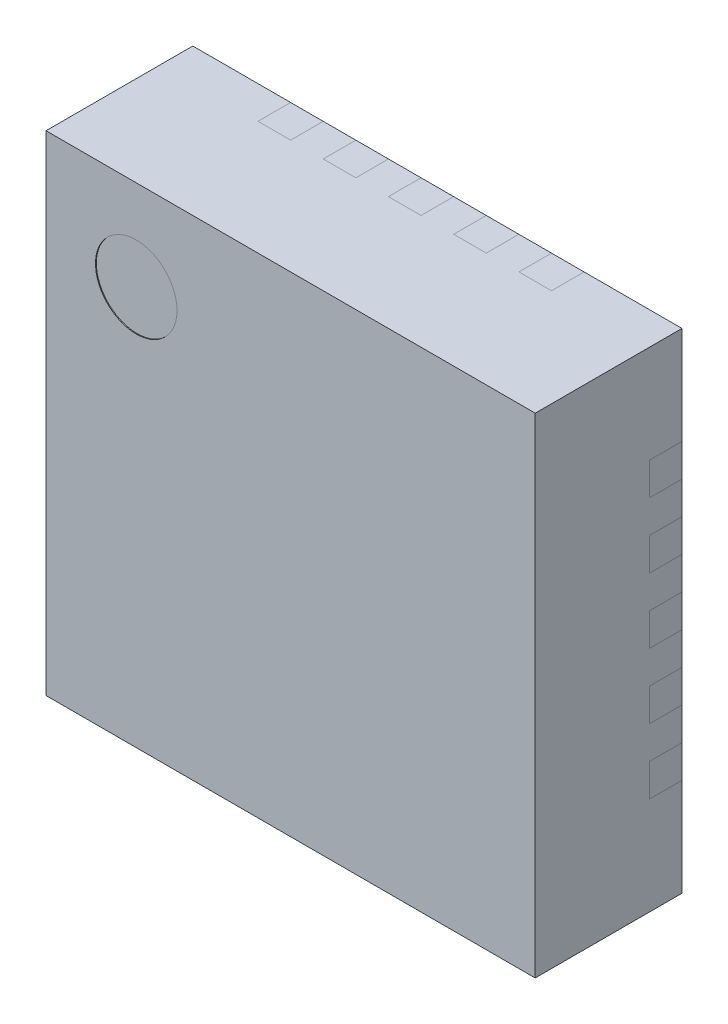
from build123d import *

# Parameters (mm, degrees)
SKETCH1_W              = 3
SKETCH1_H              = 3
BOSS_EXTRUDE1_DEPTH    = 0.9
SKETCH2_W              = 0.2
SKETCH2_H              = 0.2
CUT_EXTRUDE1_DEPTH     = 0.5
CIRPATTERN1_COUNT      = 4
SKETCH4_R              = 0.25
CUT_EXTRUDE2_DEPTH     = 0.005
SKETCH5_W              = 0.5
SKETCH5_H              = 0.2
BOSS_EXTRUDE2_DEPTH    = 0.2
BOSS_EXTRUDE2_2_DEPTH  = 0.2
BOSS_EXTRUDE2_3_DEPTH  = 0.2
BOSS_EXTRUDE2_4_DEPTH  = 0.2
BOSS_EXTRUDE2_5_DEPTH  = 0.2
SKETCH5_W_2            = 0.2
SKETCH5_H_2            = 0.5
BOSS_EXTRUDE2_6_DEPTH  = 0.2
BOSS_EXTRUDE2_7_DEPTH  = 0.2
BOSS_EXTRUDE2_8_DEPTH  = 0.2
BOSS_EXTRUDE2_9_DEPTH  = 0.2
BOSS_EXTRUDE2_10_DEPTH = 0.2
BOSS_EXTRUDE2_11_DEPTH = 0.2
BOSS_EXTRUDE2_12_DEPTH = 0.2
BOSS_EXTRUDE2_13_DEPTH = 0.2
BOSS_EXTRUDE2_14_DEPTH = 0.2
BOSS_EXTRUDE2_15_DEPTH = 0.2
BOSS_EXTRUDE2_16_DEPTH = 0.2
BOSS_EXTRUDE2_17_DEPTH = 0.2
BOSS_EXTRUDE2_18_DEPTH = 0.2
BOSS_EXTRUDE2_19_DEPTH = 0.2
BOSS_EXTRUDE2_20_DEPTH = 0.2


with BuildPart() as part:
    # Sketch1 → Boss-Extrude1 (new body)
    with BuildSketch(Plane.XY):
        Rectangle(SKETCH1_W, SKETCH1_H)
    extrude(amount=BOSS_EXTRUDE1_DEPTH)

    # Sketch2 → Cut-Extrude1 (cut)
    with BuildSketch(Plane(origin=(1.5, 0, 0), x_dir=(0, 0, -1), z_dir=(1, 0, 0))):
        with Locations((-0.1, -0.8)):
            Rectangle(SKETCH2_W, SKETCH2_H)
        with Locations((-0.1, -0.4)):
            Rectangle(SKETCH2_W, SKETCH2_H)
        with Locations((-0.1, 0)):
            Rectangle(SKETCH2_W, SKETCH2_H)
        with Locations((-0.1, 0.4)):
            Rectangle(SKETCH2_W, SKETCH2_H)
        with Locations((-0.1, 0.8)):
            Rectangle(SKETCH2_W, SKETCH2_H)
        with Locations((0.1, 0.8)):
            Rectangle(SKETCH2_W, SKETCH2_H)
        with Locations((0.1, 0.4)):
            Rectangle(SKETCH2_W, SKETCH2_H)
        with Locations((0.1, 0)):
            Rectangle(SKETCH2_W, SKETCH2_H)
        with Locations((0.1, -0.4)):
            Rectangle(SKETCH2_W, SKETCH2_H)
        with Locations((0.1, -0.8)):
            Rectangle(SKETCH2_W, SKETCH2_H)
    cut_extrude1 = extrude(amount=-CUT_EXTRUDE1_DEPTH, mode=Mode.SUBTRACT)

    # CirPattern1: Cut-Extrude1 ×4 about axis
    cirpattern1_axis = Axis((0, 0, 0), (0, 0, 1))
    for i in range(1, CIRPATTERN1_COUNT):
        add(cut_extrude1.rotate(cirpattern1_axis, i * 360 / CIRPATTERN1_COUNT), mode=Mode.SUBTRACT)

    # Sketch4 → Cut-Extrude2 (cut)
    with BuildSketch(Plane.XY.offset(0.9)):
        with Locations((-0.946643178, 0.946643178)):
            Circle(SKETCH4_R)
    extrude(amount=-CUT_EXTRUDE2_DEPTH, mode=Mode.SUBTRACT)


with BuildPart() as body_2:
    # Sketch5 → Boss-Extrude2 (new body)
    with BuildSketch(Plane(origin=(0, 0, 0.2), x_dir=(-1, 0, 0), z_dir=(0, 0, -1))):
        with Locations((-1.25, 0.8)):
            Rectangle(SKETCH5_W, SKETCH5_H)
    extrude(amount=BOSS_EXTRUDE2_DEPTH)


with BuildPart() as body_3:
    # Sketch5 → Boss-Extrude2 2 (new body)
    with BuildSketch(Plane(origin=(0, 0, 0.2), x_dir=(-1, 0, 0), z_dir=(0, 0, -1))):
        with Locations((-1.25, 0.4)):
            Rectangle(SKETCH5_W, SKETCH5_H)
    extrude(amount=BOSS_EXTRUDE2_2_DEPTH)


with BuildPart() as body_4:
    # Sketch5 → Boss-Extrude2 3 (new body)
    with BuildSketch(Plane(origin=(0, 0, 0.2), x_dir=(-1, 0, 0), z_dir=(0, 0, -1))):
        with Locations((-1.25, 0)):
            Rectangle(SKETCH5_W, SKETCH5_H)
    extrude(amount=BOSS_EXTRUDE2_3_DEPTH)


with BuildPart() as body_5:
    # Sketch5 → Boss-Extrude2 4 (new body)
    with BuildSketch(Plane(origin=(0, 0, 0.2), x_dir=(-1, 0, 0), z_dir=(0, 0, -1))):
        with Locations((-1.25, -0.4)):
            Rectangle(SKETCH5_W, SKETCH5_H)
    extrude(amount=BOSS_EXTRUDE2_4_DEPTH)


with BuildPart() as body_6:
    # Sketch5 → Boss-Extrude2 5 (new body)
    with BuildSketch(Plane(origin=(0, 0, 0.2), x_dir=(-1, 0, 0), z_dir=(0, 0, -1))):
        with Locations((-1.25, -0.8)):
            Rectangle(SKETCH5_W, SKETCH5_H)
    extrude(amount=BOSS_EXTRUDE2_5_DEPTH)


with BuildPart() as body_7:
    # Sketch5 → Boss-Extrude2 6 (new body)
    with BuildSketch(Plane(origin=(0, 0, 0.2), x_dir=(-1, 0, 0), z_dir=(0, 0, -1))):
        with Locations((-0.8, -1.25)):
            Rectangle(SKETCH5_W_2, SKETCH5_H_2)
    extrude(amount=BOSS_EXTRUDE2_6_DEPTH)


with BuildPart() as body_8:
    # Sketch5 → Boss-Extrude2 7 (new body)
    with BuildSketch(Plane(origin=(0, 0, 0.2), x_dir=(-1, 0, 0), z_dir=(0, 0, -1))):
        with Locations((-0.4, -1.25)):
            Rectangle(SKETCH5_W_2, SKETCH5_H_2)
    extrude(amount=BOSS_EXTRUDE2_7_DEPTH)


with BuildPart() as body_9:
    # Sketch5 → Boss-Extrude2 8 (new body)
    with BuildSketch(Plane(origin=(0, 0, 0.2), x_dir=(-1, 0, 0), z_dir=(0, 0, -1))):
        with Locations((0, -1.25)):
            Rectangle(SKETCH5_W_2, SKETCH5_H_2)
    extrude(amount=BOSS_EXTRUDE2_8_DEPTH)


with BuildPart() as body_10:
    # Sketch5 → Boss-Extrude2 9 (new body)
    with BuildSketch(Plane(origin=(0, 0, 0.2), x_dir=(-1, 0, 0), z_dir=(0, 0, -1))):
        with Locations((0.4, -1.25)):
            Rectangle(SKETCH5_W_2, SKETCH5_H_2)
    extrude(amount=BOSS_EXTRUDE2_9_DEPTH)


with BuildPart() as body_11:
    # Sketch5 → Boss-Extrude2 10 (new body)
    with BuildSketch(Plane(origin=(0, 0, 0.2), x_dir=(-1, 0, 0), z_dir=(0, 0, -1))):
        with Locations((0.8, -1.25)):
            Rectangle(SKETCH5_W_2, SKETCH5_H_2)
    extrude(amount=BOSS_EXTRUDE2_10_DEPTH)


with BuildPart() as body_12:
    # Sketch5 → Boss-Extrude2 11 (new body)
    with BuildSketch(Plane(origin=(0, 0, 0.2), x_dir=(-1, 0, 0), z_dir=(0, 0, -1))):
        with Locations((1.25, -0.8)):
            Rectangle(SKETCH5_W, SKETCH5_H)
    extrude(amount=BOSS_EXTRUDE2_11_DEPTH)


with BuildPart() as body_13:
    # Sketch5 → Boss-Extrude2 12 (new body)
    with BuildSketch(Plane(origin=(0, 0, 0.2), x_dir=(-1, 0, 0), z_dir=(0, 0, -1))):
        with Locations((1.25, -0.4)):
            Rectangle(SKETCH5_W, SKETCH5_H)
    extrude(amount=BOSS_EXTRUDE2_12_DEPTH)


with BuildPart() as body_14:
    # Sketch5 → Boss-Extrude2 13 (new body)
    with BuildSketch(Plane(origin=(0, 0, 0.2), x_dir=(-1, 0, 0), z_dir=(0, 0, -1))):
        with Locations((1.25, 0)):
            Rectangle(SKETCH5_W, SKETCH5_H)
    extrude(amount=BOSS_EXTRUDE2_13_DEPTH)


with BuildPart() as body_15:
    # Sketch5 → Boss-Extrude2 14 (new body)
    with BuildSketch(Plane(origin=(0, 0, 0.2), x_dir=(-1, 0, 0), z_dir=(0, 0, -1))):
        with Locations((1.25, 0.4)):
            Rectangle(SKETCH5_W, SKETCH5_H)
    extrude(amount=BOSS_EXTRUDE2_14_DEPTH)


with BuildPart() as body_16:
    # Sketch5 → Boss-Extrude2 15 (new body)
    with BuildSketch(Plane(origin=(0, 0, 0.2), x_dir=(-1, 0, 0), z_dir=(0, 0, -1))):
        with Locations((1.25, 0.8)):
            Rectangle(SKETCH5_W, SKETCH5_H)
    extrude(amount=BOSS_EXTRUDE2_15_DEPTH)


with BuildPart() as body_17:
    # Sketch5 → Boss-Extrude2 16 (new body)
    with BuildSketch(Plane(origin=(0, 0, 0.2), x_dir=(-1, 0, 0), z_dir=(0, 0, -1))):
        with Locations((0.8, 1.25)):
            Rectangle(SKETCH5_W_2, SKETCH5_H_2)
    extrude(amount=BOSS_EXTRUDE2_16_DEPTH)


with BuildPart() as body_18:
    # Sketch5 → Boss-Extrude2 17 (new body)
    with BuildSketch(Plane(origin=(0, 0, 0.2), x_dir=(-1, 0, 0), z_dir=(0, 0, -1))):
        with Locations((0.4, 1.25)):
            Rectangle(SKETCH5_W_2, SKETCH5_H_2)
    extrude(amount=BOSS_EXTRUDE2_17_DEPTH)


with BuildPart() as body_19:
    # Sketch5 → Boss-Extrude2 18 (new body)
    with BuildSketch(Plane(origin=(0, 0, 0.2), x_dir=(-1, 0, 0), z_dir=(0, 0, -1))):
        with Locations((0, 1.25)):
            Rectangle(SKETCH5_W_2, SKETCH5_H_2)
    extrude(amount=BOSS_EXTRUDE2_18_DEPTH)


with BuildPart() as body_20:
    # Sketch5 → Boss-Extrude2 19 (new body)
    with BuildSketch(Plane(origin=(0, 0, 0.2), x_dir=(-1, 0, 0), z_dir=(0, 0, -1))):
        with Locations((-0.4, 1.25)):
            Rectangle(SKETCH5_W_2, SKETCH5_H_2)
    extrude(amount=BOSS_EXTRUDE2_19_DEPTH)


with BuildPart() as body_21:
    # Sketch5 → Boss-Extrude2 20 (new body)
    with BuildSketch(Plane(origin=(0, 0, 0.2), x_dir=(-1, 0, 0), z_dir=(0, 0, -1))):
        with Locations((-0.8, 1.25)):
            Rectangle(SKETCH5_W_2, SKETCH5_H_2)
    extrude(amount=BOSS_EXTRUDE2_20_DEPTH)


solid = Compound([part.part, body_2.part, body_3.part, body_4.part, body_5.part, body_6.part, body_7.part, body_8.part, body_9.part, body_10.part, body_11.part, body_12.part, body_13.part, body_14.part, body_15.part, body_16.part, body_17.part, body_18.part, body_19.part, body_20.part, body_21.part])
